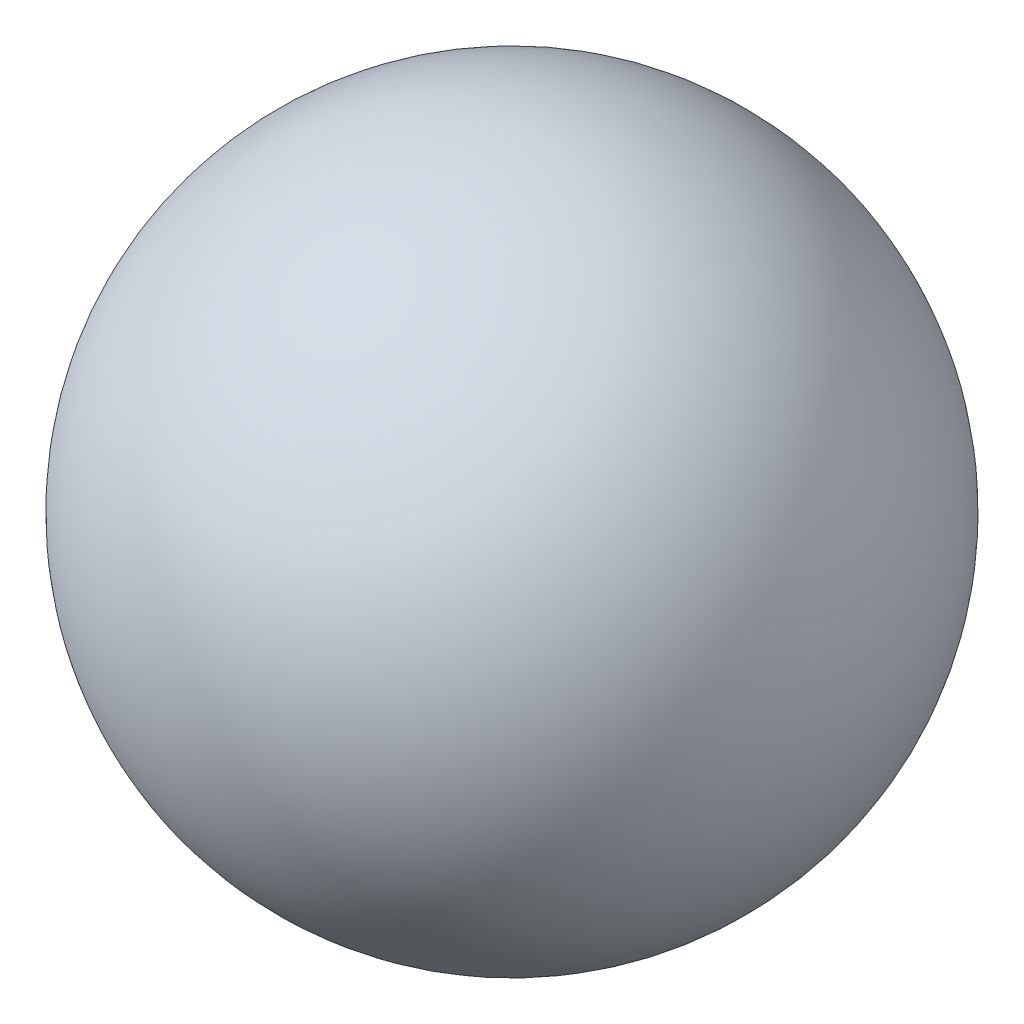
from build123d import *


with BuildPart() as part:
    # Sketch3 → Revolve1 (revolve)
    with BuildSketch(Plane(origin=(0, 0, 0), x_dir=(1, 0, 0), z_dir=(0, 1, 0))):
        with BuildLine():
            Line((0, 20), (0, -20))
            ThreePointArc((0, -20), (-20, 0), (0, 20))
        make_face()
    revolve(axis=Axis((0, 0, -20), (0, 0, 1)))


solid = part.part
